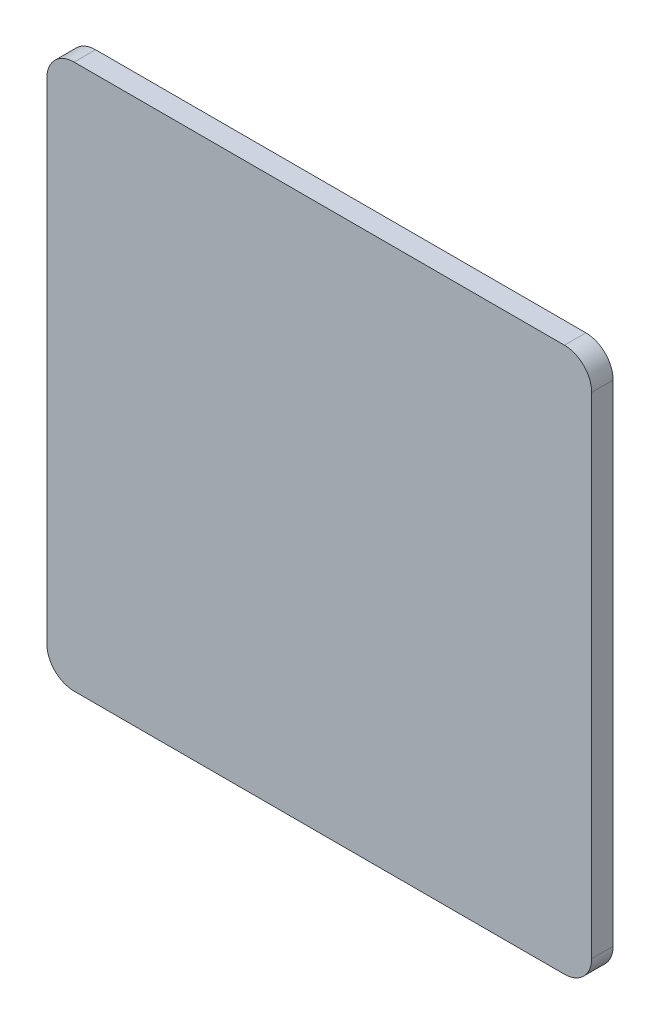
from build123d import *

# Parameters (mm, degrees)
SKETCH1_W           = 127
SKETCH1_H           = 127
SKETCH1_W_2         = 121
SKETCH1_H_2         = 121
SKETCH1_R           = 38.5
BOSS_EXTRUDE1_DEPTH = 5
FILLET1_R           = 6.35


with BuildPart() as part:
    # Sketch1 → Boss-Extrude1 (new body)
    with BuildSketch(Plane.XY):
        Rectangle(SKETCH1_W, SKETCH1_H)
        Rectangle(SKETCH1_W_2, SKETCH1_H_2, mode=Mode.SUBTRACT)
        Rectangle(SKETCH1_W_2, SKETCH1_H_2)
        Circle(SKETCH1_R, mode=Mode.SUBTRACT)
        Circle(SKETCH1_R)
    extrude(amount=BOSS_EXTRUDE1_DEPTH)

    # Fillet1
    fillet1_edges = [part.edges().sort_by_distance(p)[0] for p in [
        (-63.5, 63.5, 2.5),
        (63.5, 63.5, 2.5),
        (63.5, -63.5, 2.5),
        (-63.5, -63.5, 2.5),
    ]]
    fillet(fillet1_edges, radius=FILLET1_R)


solid = part.part
